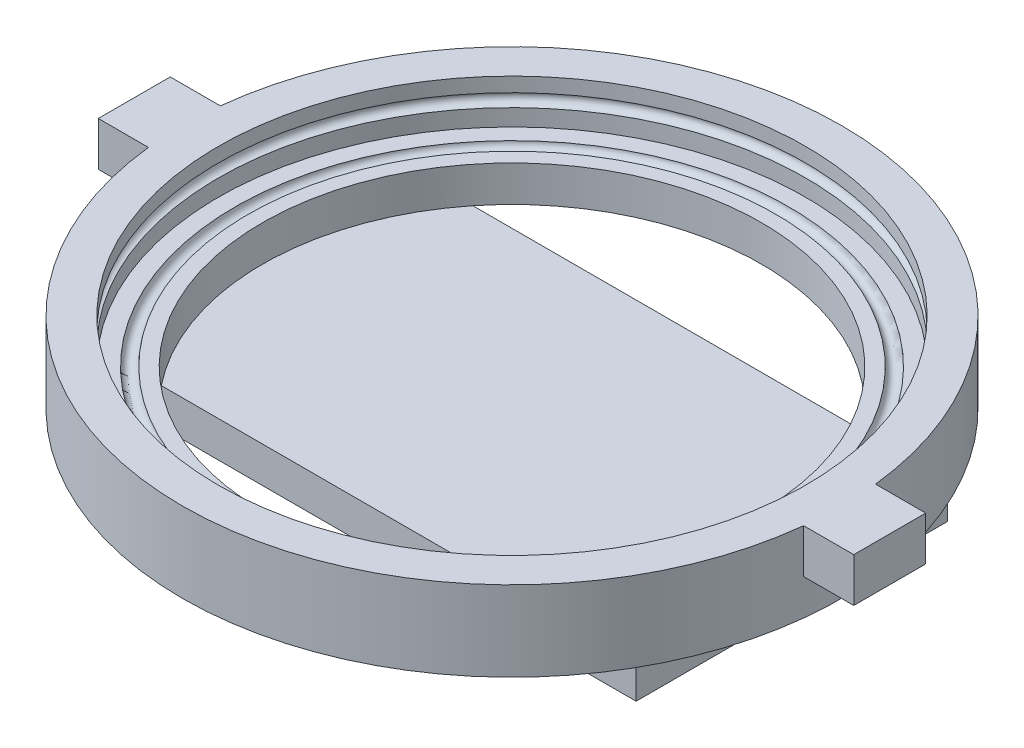
from build123d import *

# Parameters (mm, degrees)
SKETCH2_W           = 197.612
SKETCH2_H           = 109.982
BOSS_EXTRUDE1_DEPTH = 12.7
SKETCH3_W           = 19.05
SKETCH3_H           = 25.4
BOSS_EXTRUDE2_DEPTH = 15.5575


with BuildPart() as part:
    # Sketch1 → Revolve1 (revolve)
    with BuildSketch(Plane.XY):
        with BuildLine():
            Line((103.6447, -10.668), (103.6447, -15.748))
            ThreePointArc((103.6447, -15.748), (105.9307, -18.034), (103.6447, -20.32))
            Line((103.6447, -20.32), (103.6447, -26.2255))
            Line((103.6447, -26.2255), (97.7392, -26.2255))
            ThreePointArc((97.7392, -26.2255), (95.4532, -28.5115), (93.1672, -26.2255))
            Line((93.1672, -26.2255), (88.0872, -26.2255))
            Line((88.0872, -26.2255), (88.0872, -38.9255))
            Line((88.0872, -38.9255), (116.3447, -38.9255))
            Line((116.3447, -38.9255), (116.3447, -10.668))
            Line((116.3447, -10.668), (103.6447, -10.668))
        make_face()
    revolve(axis=Axis((0, 0, 0), (0, -1, 0)))

    # Sketch2 → Boss-Extrude1 (add)
    with BuildSketch(Plane.XZ.offset(38.9255)):
        Rectangle(SKETCH2_W, SKETCH2_H)
    extrude(amount=BOSS_EXTRUDE1_DEPTH)

    # Sketch3 → Boss-Extrude2 (add)
    with BuildSketch(Plane(origin=(0, -10.668, 0), x_dir=(1, 0, 0), z_dir=(0, 1, 0))):
        with Locations((123.825, 0)):
            Rectangle(SKETCH3_W, SKETCH3_H)
        with Locations((-123.825, 0)):
            Rectangle(SKETCH3_W, SKETCH3_H)
    extrude(amount=-BOSS_EXTRUDE2_DEPTH)


solid = part.part
